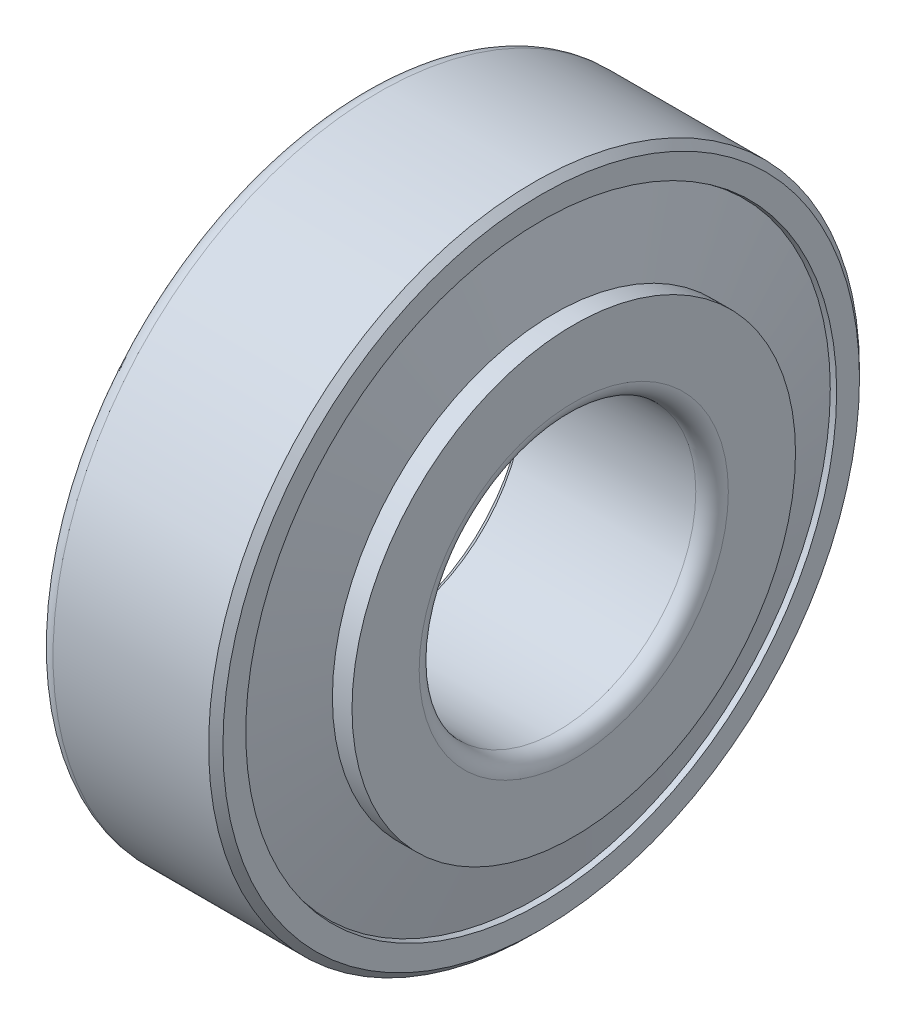
from build123d import *


with BuildPart() as part:
    # OutRacSke → OuterRace (revolve)
    with BuildSketch(Plane.XY):
        with BuildLine():
            Line((-2, 18.15674466), (-13, 15.704))
            Line((-13, 15.704), (-13, 19))
            ThreePointArc((-13, 19), (-12.707106781, 19.707106781), (-12, 20))
            Line((-12, 20), (-2.44, 20))
            Line((-2.44, 20), (-2, 19.56))
            Line((-2, 19.56), (-2, 18.15674466))
        make_face()
    revolve(axis=Axis((-42.5, 0, 0), (1, 0, 0)))

    # RolSimSke → RollersSimplified (revolve)
    with BuildSketch(Plane.XY):
        Polygon((-12, 16.006611671), (-2.337294608, 18.161170676), (-1.211047855, 13.110211039), (-10.873753248, 10.955652034), align=None)
    revolve(axis=Axis((0, 0, 0), (-1, 0, 0)))

    # InsRacSke → InnerRace (revolve)
    with BuildSketch(Plane.XY):
        with BuildLine():
            Line((-10.925817259, 11.214402034), (-12, 11.214402034))
            Line((-12, 11.214402034), (-12, 8.94))
            Line((-12, 8.94), (-11.56, 8.5))
            Line((-11.56, 8.5), (-1, 8.5))
            ThreePointArc((-1, 8.5), (-0.292893219, 8.792893219), (0, 9.5))
            Line((0, 9.5), (0, 13.627711039))
            Line((0, 13.627711039), (-1.205416623, 13.627711039))
            Line((-1.205416623, 13.627711039), (-1.205416623, 13.110211039))
            Line((-1.205416623, 13.110211039), (-10.868122015, 10.955652034))
            Line((-10.868122015, 10.955652034), (-10.925817259, 11.214402034))
        make_face()
    revolve(axis=Axis((-42.5, 0, 0), (1, 0, 0)))


solid = part.part
